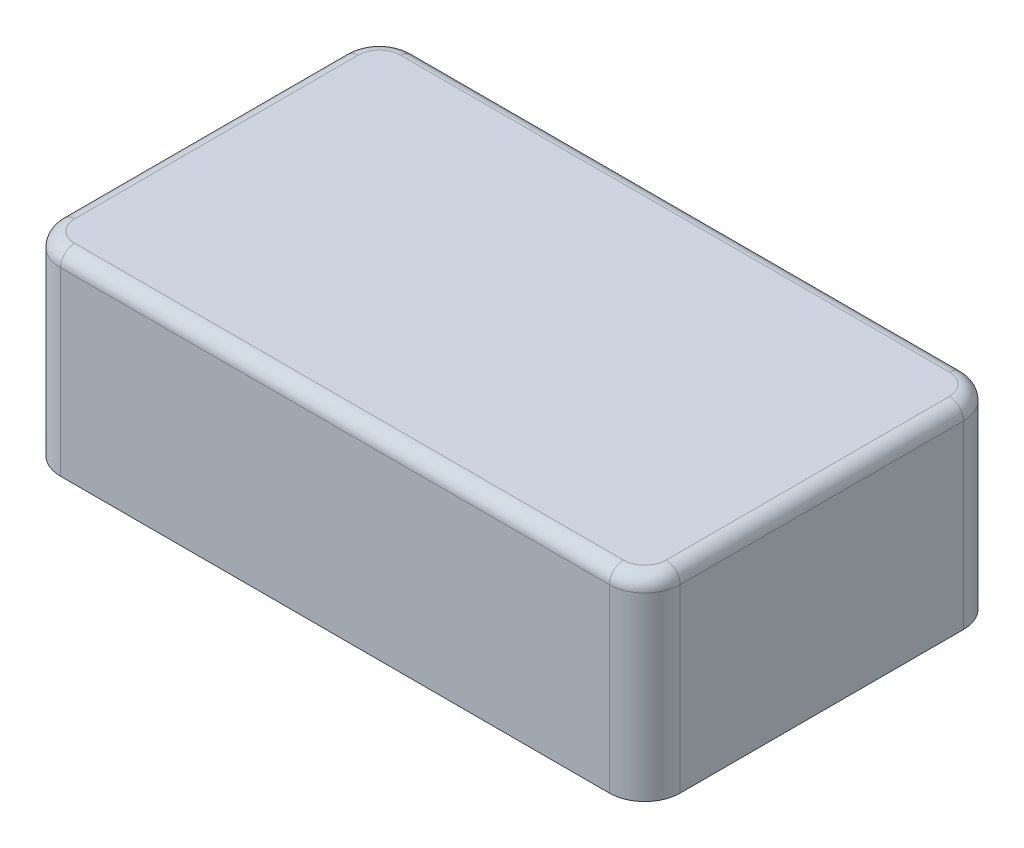
from build123d import *

# Parameters (mm, degrees)
BOSS_EXTRU_1_DEPTH = 1.1
CONG_1_R           = 0.08


with BuildPart() as part:
    # Esquisse1 → Boss.-Extru.1 (new body)
    with BuildSketch(Plane(origin=(0, 0, 0), x_dir=(1, 0, 0), z_dir=(0, 1, 0))):
        with BuildLine():
            Line((1.55, -1), (-1.55, -1))
            ThreePointArc((-1.55, -1), (-1.691421356, -0.941421356), (-1.75, -0.8))
            Line((-1.75, -0.8), (-1.75, 0.8))
            ThreePointArc((-1.75, 0.8), (-1.691421356, 0.941421356), (-1.55, 1))
            Line((-1.55, 1), (1.55, 1))
            ThreePointArc((1.55, 1), (1.691421356, 0.941421356), (1.75, 0.8))
            Line((1.75, 0.8), (1.75, -0.8))
            ThreePointArc((1.75, -0.8), (1.691421356, -0.941421356), (1.55, -1))
        make_face()
    extrude(amount=BOSS_EXTRU_1_DEPTH)

    # Congé1
    cong_1_edges = [part.edges().sort_by_distance(p)[0] for p in [
        (-1.691421356, 1.1, -0.941421356),
        (-1.75, 1.1, 0),
        (-1.691421356, 1.1, 0.941421356),
        (0, 1.1, 1),
        (1.691421356, 1.1, 0.941421356),
        (1.75, 1.1, 0),
        (1.691421356, 1.1, -0.941421356),
        (0, 1.1, -1),
    ]]
    fillet(cong_1_edges, radius=CONG_1_R)


solid = part.part
